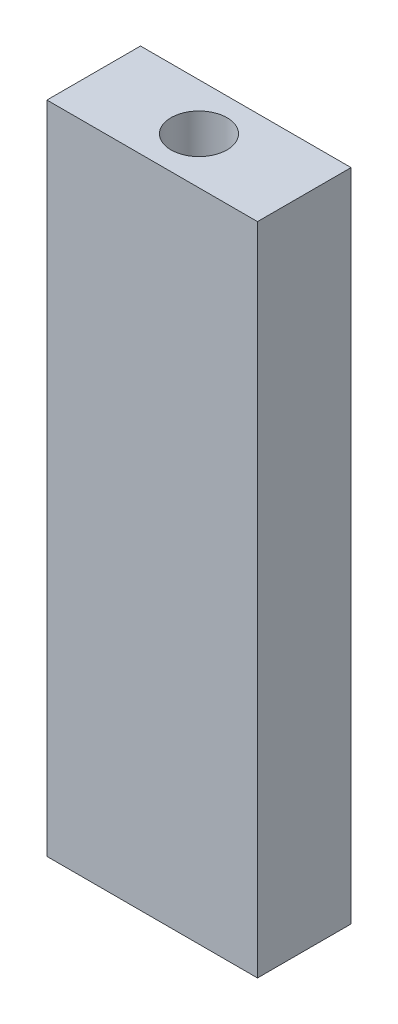
from build123d import *

# Parameters (mm, degrees)
SKETCH1_W                 = 14.2875
SKETCH1_H                 = 6.35
EXTRUDE1_DEPTH            = 44.45
F_6_CLEARANCE_HOLE1_D     = 3.7973
F_6_CLEARANCE_HOLE1_DEPTH = 6.35
F_6_CLEARANCE_HOLE1_TIP   = 1.140824014
F_6_CLEARANCE_HOLE2_D     = 3.7973
F_6_CLEARANCE_HOLE2_DEPTH = 6.35
F_6_CLEARANCE_HOLE2_TIP   = 1.140824014


with BuildPart() as part:
    # Sketch1 → Extrude1 (new body)
    with BuildSketch(Plane(origin=(0, 0, 0), x_dir=(1, 0, 0), z_dir=(0, 1, 0))):
        with Locations((-45.973078165, 33.616731266)):
            Rectangle(SKETCH1_W, SKETCH1_H)
    extrude(amount=EXTRUDE1_DEPTH)

    # #6 Clearance Hole1
    with Locations(Plane(origin=(0, 44.45, 0), x_dir=(-1, 0, 0), z_dir=(0, 1, 0))):
        with Locations((45.973078165, -33.616731266)):
            Hole(F_6_CLEARANCE_HOLE1_D / 2, depth=F_6_CLEARANCE_HOLE1_DEPTH)
            with Locations((0, 0, -(F_6_CLEARANCE_HOLE1_DEPTH + F_6_CLEARANCE_HOLE1_TIP / 2))):  # 118° drill point
                Cone(0, F_6_CLEARANCE_HOLE1_D / 2, F_6_CLEARANCE_HOLE1_TIP, mode=Mode.SUBTRACT)

    # #6 Clearance Hole2
    with Locations(Plane(origin=(-45.973078165, 0, -33.616731266), x_dir=(0, 0, -1), z_dir=(0, -1, 0))):
        with Locations((0, 0)):
            Hole(F_6_CLEARANCE_HOLE2_D / 2, depth=F_6_CLEARANCE_HOLE2_DEPTH)
            with Locations((0, 0, -(F_6_CLEARANCE_HOLE2_DEPTH + F_6_CLEARANCE_HOLE2_TIP / 2))):  # 118° drill point
                Cone(0, F_6_CLEARANCE_HOLE2_D / 2, F_6_CLEARANCE_HOLE2_TIP, mode=Mode.SUBTRACT)


solid = part.part
